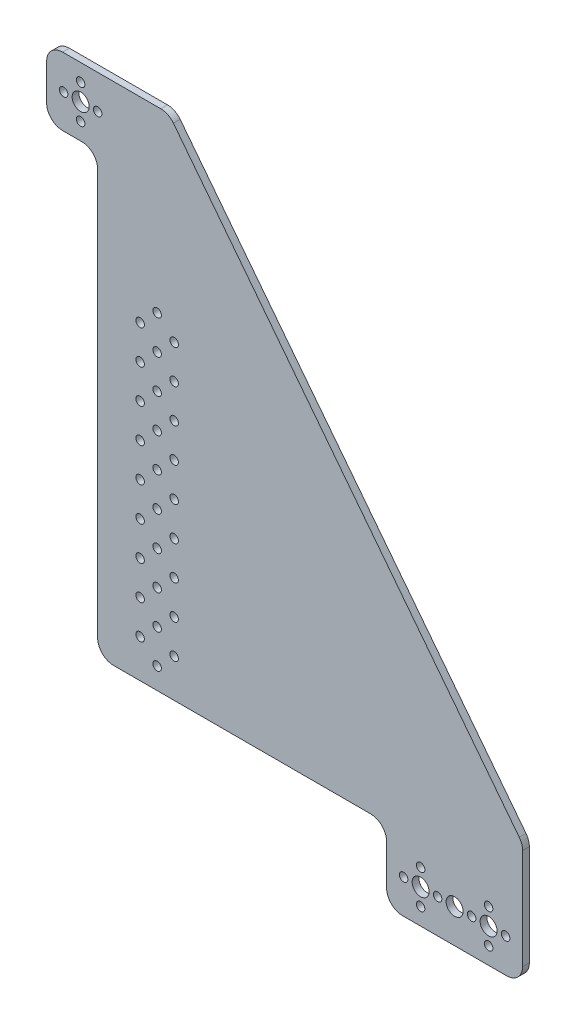
from build123d import *

# Parameters (mm, degrees)
SKETCH1_R           = 4
SKETCH1_R_2         = 2
BOSS_EXTRUDE1_DEPTH = 3.175


with BuildPart() as part:
    # Sketch1 → Boss-Extrude1 (new body)
    with BuildSketch(Plane.XY):
        with BuildLine():
            Line((144, -229.5), (144, -248.5))
            ThreePointArc((144, -248.5), (146.196699141, -253.803300859), (151.5, -256))
            Line((151.5, -256), (200.5, -256))
            ThreePointArc((200.5, -256), (205.803300859, -253.803300859), (208, -248.5))
            Line((208, -248.5), (208, -201.169519945))
            ThreePointArc((208, -201.169519945), (207.595148356, -198.73870325), (206.424301385, -196.570318591))
            Line((206.424301385, -196.570318591), (43.651971362, 13.099201355))
            ThreePointArc((43.651971362, 13.099201355), (41.025850524, 15.235874485), (37.727669977, 16))
            Line((37.727669977, 16), (-8.5, 16))
            ThreePointArc((-8.5, 16), (-13.803300859, 13.803300859), (-16, 8.5))
            Line((-16, 8.5), (-16, -8.5))
            ThreePointArc((-16, -8.5), (-13.803300859, -13.803300859), (-8.5, -16))
            Line((-8.5, -16), (0.5, -16))
            ThreePointArc((0.5, -16), (5.803300859, -18.196699141), (8, -23.5))
            Line((8, -23.5), (8, -214.5))
            ThreePointArc((8, -214.5), (10.196699141, -219.803300859), (15.5, -222))
            Line((15.5, -222), (136.5, -222))
            ThreePointArc((136.5, -222), (141.803300859, -224.196699141), (144, -229.5))
        make_face()
        Circle(SKETCH1_R, mode=Mode.SUBTRACT)
        with Locations((0, 8)):
            Circle(SKETCH1_R_2, mode=Mode.SUBTRACT)
        with Locations((160, -240)):
            Circle(SKETCH1_R, mode=Mode.SUBTRACT)
        with Locations((176, -240)):
            Circle(SKETCH1_R, mode=Mode.SUBTRACT)
        with Locations((160, -232)):
            Circle(SKETCH1_R_2, mode=Mode.SUBTRACT)
        with Locations((168, -240)):
            Circle(SKETCH1_R_2, mode=Mode.SUBTRACT)
        with Locations((160, -248)):
            Circle(SKETCH1_R_2, mode=Mode.SUBTRACT)
        with Locations((152, -240)):
            Circle(SKETCH1_R_2, mode=Mode.SUBTRACT)
        with Locations((200, -240)):
            Circle(SKETCH1_R_2, mode=Mode.SUBTRACT)
        with Locations((192, -248)):
            Circle(SKETCH1_R_2, mode=Mode.SUBTRACT)
        with Locations((192, -240)):
            Circle(SKETCH1_R, mode=Mode.SUBTRACT)
        with Locations((184, -240)):
            Circle(SKETCH1_R_2, mode=Mode.SUBTRACT)
        with Locations((192, -232)):
            Circle(SKETCH1_R_2, mode=Mode.SUBTRACT)
        with Locations((8, 0)):
            Circle(SKETCH1_R_2, mode=Mode.SUBTRACT)
        with Locations((0, -8)):
            Circle(SKETCH1_R_2, mode=Mode.SUBTRACT)
        with Locations((-8, 0)):
            Circle(SKETCH1_R_2, mode=Mode.SUBTRACT)
        with Locations((36, -212)):
            Circle(SKETCH1_R_2, mode=Mode.SUBTRACT)
        with Locations((28, -204)):
            Circle(SKETCH1_R_2, mode=Mode.SUBTRACT)
        with Locations((36, -196)):
            Circle(SKETCH1_R_2, mode=Mode.SUBTRACT)
        with Locations((44, -204)):
            Circle(SKETCH1_R_2, mode=Mode.SUBTRACT)
        with Locations((44, -188)):
            Circle(SKETCH1_R_2, mode=Mode.SUBTRACT)
        with Locations((36, -180)):
            Circle(SKETCH1_R_2, mode=Mode.SUBTRACT)
        with Locations((28, -188)):
            Circle(SKETCH1_R_2, mode=Mode.SUBTRACT)
        with Locations((44, -172)):
            Circle(SKETCH1_R_2, mode=Mode.SUBTRACT)
        with Locations((36, -164)):
            Circle(SKETCH1_R_2, mode=Mode.SUBTRACT)
        with Locations((28, -172)):
            Circle(SKETCH1_R_2, mode=Mode.SUBTRACT)
        with Locations((44, -156)):
            Circle(SKETCH1_R_2, mode=Mode.SUBTRACT)
        with Locations((36, -148)):
            Circle(SKETCH1_R_2, mode=Mode.SUBTRACT)
        with Locations((28, -156)):
            Circle(SKETCH1_R_2, mode=Mode.SUBTRACT)
        with Locations((44, -140)):
            Circle(SKETCH1_R_2, mode=Mode.SUBTRACT)
        with Locations((36, -132)):
            Circle(SKETCH1_R_2, mode=Mode.SUBTRACT)
        with Locations((28, -140)):
            Circle(SKETCH1_R_2, mode=Mode.SUBTRACT)
        with Locations((44, -124)):
            Circle(SKETCH1_R_2, mode=Mode.SUBTRACT)
        with Locations((36, -116)):
            Circle(SKETCH1_R_2, mode=Mode.SUBTRACT)
        with Locations((28, -124)):
            Circle(SKETCH1_R_2, mode=Mode.SUBTRACT)
        with Locations((44, -108)):
            Circle(SKETCH1_R_2, mode=Mode.SUBTRACT)
        with Locations((36, -100)):
            Circle(SKETCH1_R_2, mode=Mode.SUBTRACT)
        with Locations((28, -108)):
            Circle(SKETCH1_R_2, mode=Mode.SUBTRACT)
        with Locations((44, -92)):
            Circle(SKETCH1_R_2, mode=Mode.SUBTRACT)
        with Locations((36, -84)):
            Circle(SKETCH1_R_2, mode=Mode.SUBTRACT)
        with Locations((28, -92)):
            Circle(SKETCH1_R_2, mode=Mode.SUBTRACT)
        with Locations((44, -76)):
            Circle(SKETCH1_R_2, mode=Mode.SUBTRACT)
        with Locations((36, -68)):
            Circle(SKETCH1_R_2, mode=Mode.SUBTRACT)
        with Locations((28, -76)):
            Circle(SKETCH1_R_2, mode=Mode.SUBTRACT)
    extrude(amount=BOSS_EXTRUDE1_DEPTH)


solid = part.part
